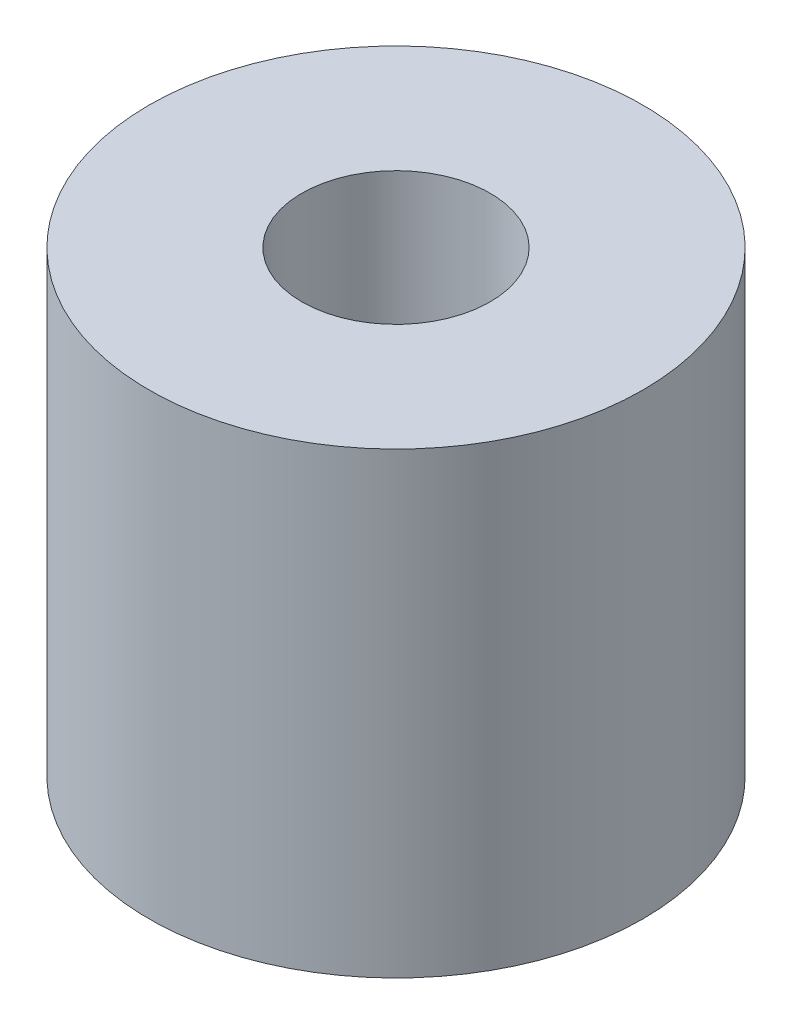
from build123d import *

# Parameters (mm, degrees)
SKETCH_1_R      = 4.85
SKETCH_1_R_2    = 1.85
EXTRUDE_1_DEPTH = 9


with BuildPart() as part:
    # 草图1 → 拉伸-薄壁1 (new body)
    with BuildSketch(Plane(origin=(0, 0, 0), x_dir=(1, 0, 0), z_dir=(0, 1, 0))):
        Circle(SKETCH_1_R)
        Circle(SKETCH_1_R_2, mode=Mode.SUBTRACT)
    extrude(amount=EXTRUDE_1_DEPTH)


solid = part.part
